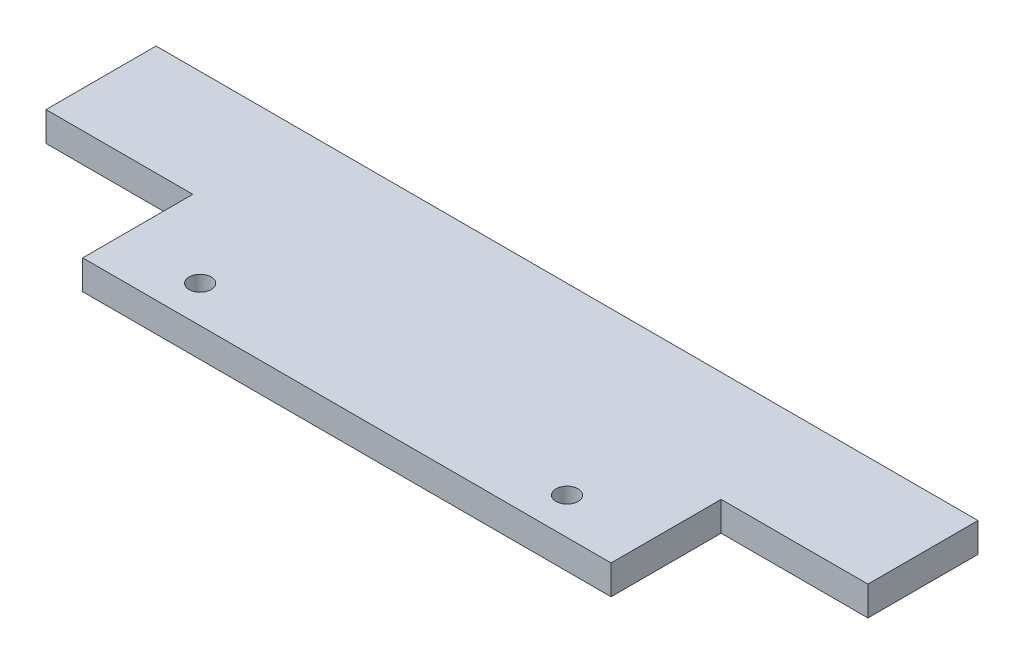
from build123d import *

# Parameters (mm, degrees)
SKETCH1_W           = 72
SKETCH1_H           = 30
BOSS_EXTRUDE1_DEPTH = 4
SKETCH2_R           = 1.5
CUT_EXTRUDE1_DEPTH  = 4
SKETCH3_W           = 20
SKETCH3_H           = 15
BOSS_EXTRUDE3_DEPTH = 4


with BuildPart() as part:
    # Sketch1 → Boss-Extrude1 (new body)
    with BuildSketch(Plane(origin=(0, 0, 0), x_dir=(1, 0, 0), z_dir=(0, 1, 0))):
        with Locations((3.82122905, -1.340782123)):
            Rectangle(SKETCH1_W, SKETCH1_H)
    extrude(amount=BOSS_EXTRUDE1_DEPTH)

    # Sketch2 → Cut-Extrude1 (cut)
    with BuildSketch(Plane(origin=(0, 4, 0), x_dir=(1, 0, 0), z_dir=(0, 1, 0))):
        with Locations((-21.17877095, -11.340782123)):
            Circle(SKETCH2_R)
        with Locations((28.82122905, -11.340782123)):
            Circle(SKETCH2_R)
    extrude(amount=-CUT_EXTRUDE1_DEPTH, mode=Mode.SUBTRACT)

    # Sketch3 → Boss-Extrude3 (add)
    with BuildSketch(Plane(origin=(0, 4, 0), x_dir=(1, 0, 0), z_dir=(0, 1, 0))):
        with Locations((49.82122905, 6.159217877)):
            Rectangle(SKETCH3_W, SKETCH3_H)
        with Locations((-42.17877095, 6.159217877)):
            Rectangle(SKETCH3_W, SKETCH3_H)
    extrude(amount=-BOSS_EXTRUDE3_DEPTH)


solid = part.part
